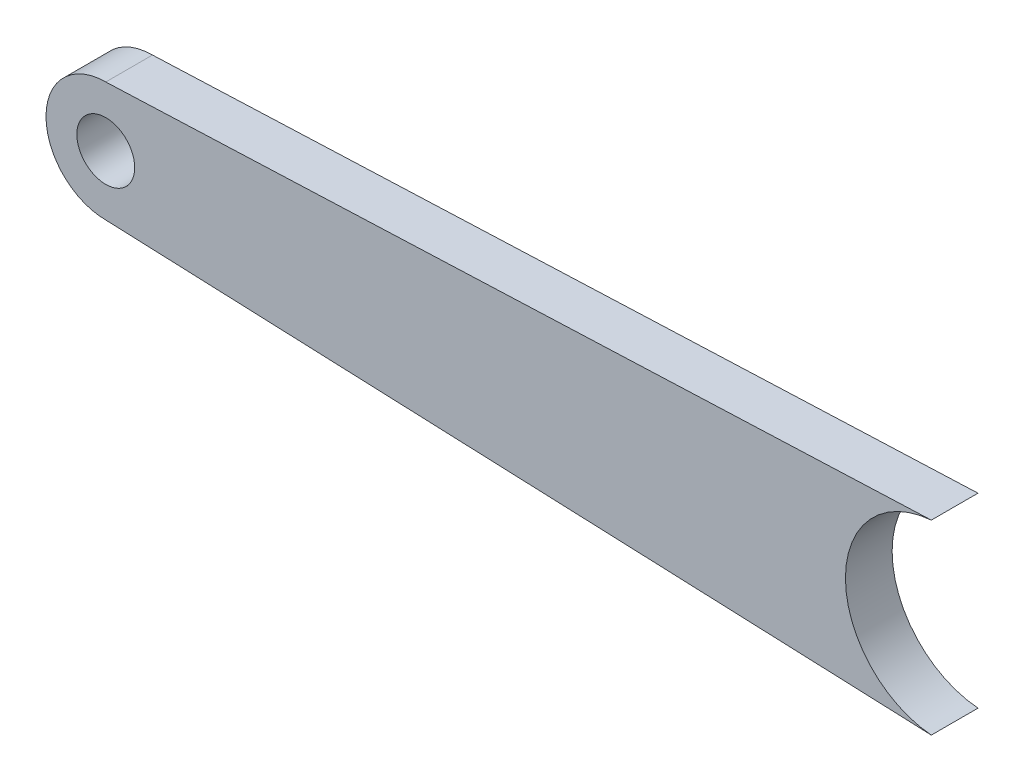
from build123d import *

# Parameters (mm, degrees)
SKETCH1_R           = 8.128
SKETCH1_R_2         = 3.937
BOSS_EXTRUDE1_DEPTH = 6.35
BOSS_EXTRUDE2_DEPTH = 6.35


with BuildPart() as part:
    # Sketch1 → Boss-Extrude1 (new body)
    with BuildSketch(Plane.XY):
        Circle(SKETCH1_R)
        Circle(SKETCH1_R_2, mode=Mode.SUBTRACT)
    extrude(amount=BOSS_EXTRUDE1_DEPTH)

    # Sketch2 → Boss-Extrude2 (add)
    with BuildSketch(Plane.XY.offset(6.35)):
        with BuildLine():
            Line((112.260554909, 12.658695041), (0, 8.128))
            ThreePointArc((0, 8.128), (5.747363917, 5.747363917), (8.128, 0))
            ThreePointArc((8.128, 0), (5.747363917, -5.747363917), (0, -8.128))
            Line((0, -8.128), (112.260554909, -12.658695041))
            ThreePointArc((112.260554909, -12.658695041), (100.584, 0), (112.260554909, 12.658695041))
        make_face()
    extrude(amount=-BOSS_EXTRUDE2_DEPTH)


solid = part.part
